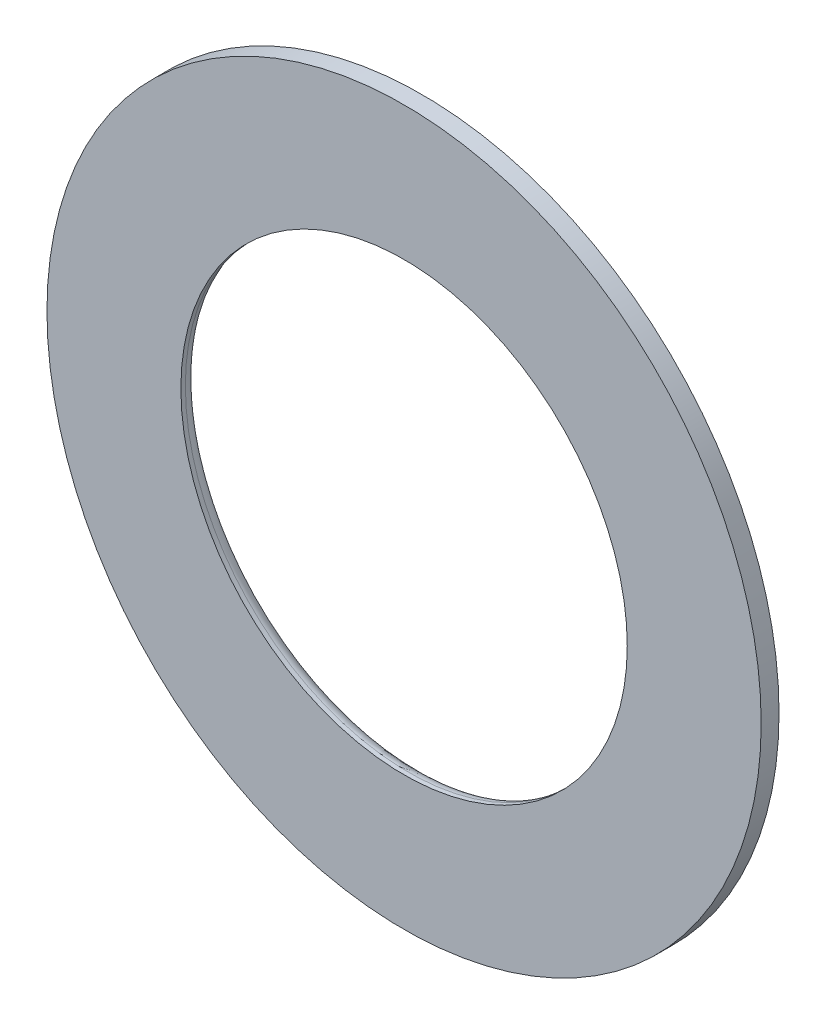
from build123d import *

# Parameters (mm, degrees)
SKETCH1_R           = 40
SKETCH1_R_2         = 25
BOSS_EXTRUDE1_DEPTH = 2
FILLET2_R           = 1.5


with BuildPart() as part:
    # Sketch1 → Boss-Extrude1 (new body)
    with BuildSketch(Plane.XY):
        Circle(SKETCH1_R)
        Circle(SKETCH1_R_2, mode=Mode.SUBTRACT)
    extrude(amount=BOSS_EXTRUDE1_DEPTH)

    # Fillet2
    fillet2_edges = [part.edges().sort_by_distance(p)[0] for p in [
        (-25, 0, 0),
    ]]
    fillet(fillet2_edges, radius=FILLET2_R)


solid = part.part
